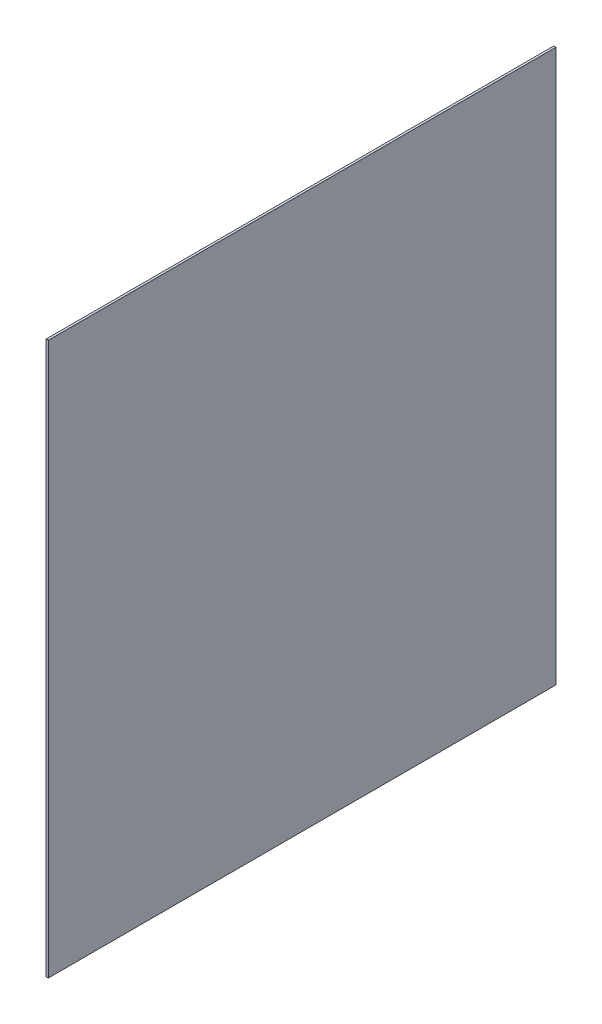
from build123d import *

# Parameters (mm, degrees)
SZKIC1_W                    = 340
SZKIC1_H                    = 370
DODANIE_WYCI_GNI_CIE1_DEPTH = 1.5


with BuildPart() as part:
    # Szkic1 → Dodanie-wyciągnięcie1 (new body)
    with BuildSketch(Plane(origin=(662.5, 0, 0), x_dir=(0, 0, -1), z_dir=(1, 0, 0))):
        with Locations((-270, 0)):
            Rectangle(SZKIC1_W, SZKIC1_H)
    extrude(amount=DODANIE_WYCI_GNI_CIE1_DEPTH)


solid = part.part
